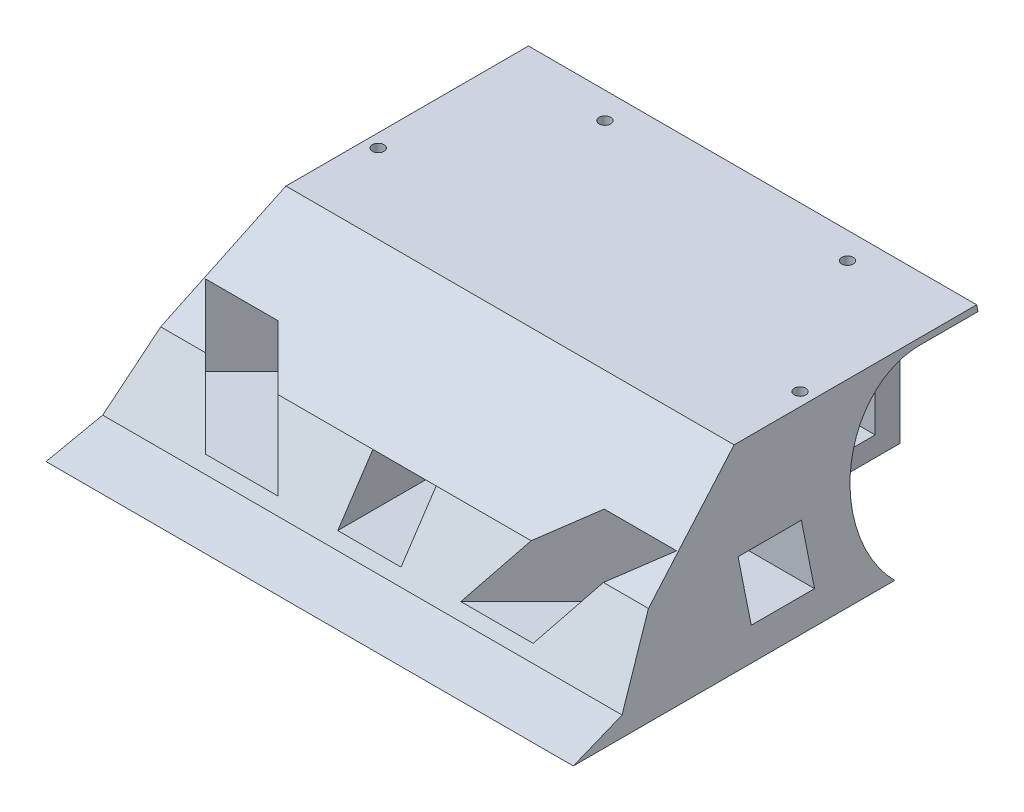
from build123d import *

# Parameters (mm, degrees)
IZIM2_W                       = 100
IZIM2_H                       = 90
Y_KSEKLIK_EKSTR_ZYON1_DEPTH   = 30
KES_EKSTR_ZYON11_DEPTH        = 22
KES_EKSTR_ZYON12_DEPTH        = 22
IZIM7_W                       = 12.5
IZIM7_H                       = 16.5
KES_EKSTR_ZYON13_DEPTH        = 70
IZIM8_W                       = 6
IZIM8_H                       = 30
KES_EKSTR_ZYON14_DEPTH        = 100
IZIM9_W                       = 22
IZIM9_H                       = 6
KES_EKSTR_ZYON15_DEPTH        = 100
IZIM10_W                      = 12
IZIM10_H                      = 10
KES_EKSTR_ZYON16_DEPTH        = 100
IZIM11_W                      = 12
IZIM11_H                      = 10
KES_EKSTR_ZYON17_DEPTH        = 45
Y_KSEKLIK_EKSTR_ZYON2_DEPTH   = 45
Y_KSEKLIK_EKSTR_ZYON2_2_DEPTH = 45
IZIM13_W                      = 9.7
IZIM13_H                      = 15.2
KES_EKSTR_ZYON18_DEPTH        = 45
IZIM14_W                      = 9.7
IZIM14_H                      = 15.2
KES_EKSTR_ZYON19_DEPTH        = 45
IZIM15_W                      = 64.648209686
IZIM15_H                      = 50.718484946
KES_EKSTR_ZYON20_DEPTH        = 45
KES_EKSTR_ZYON21_DEPTH        = 100
IZIM17_R                      = 1.1
KES_EKSTR_ZYON24_DEPTH        = 100
KES_EKSTR_ZYON25_DEPTH        = 100


with BuildPart() as part:
    # Çizim2 → Yükseklik-Ekstrüzyon1 (new body)
    with BuildSketch(Plane(origin=(0, 0, 0), x_dir=(1, 0, 0), z_dir=(0, 1, 0))):
        with Locations((-5.3298184, 8.1959709)):
            Rectangle(IZIM2_W, IZIM2_H)
    extrude(amount=Y_KSEKLIK_EKSTR_ZYON1_DEPTH)

    # Çizim5 → Kes-Ekstrüzyon11 (cut)
    with BuildSketch(Plane(origin=(44.6701816, 0, 0), x_dir=(0, 0, -1), z_dir=(1, 0, 0))):
        with BuildLine():
            Line((36.1959709, 29), (53.1959709, 29))
            Line((53.1959709, 29), (53.1959709, 0))
            Line((53.1959709, 0), (24.154376321, 0))
            ThreePointArc((24.154376321, 0), (20.495652432, 18.519202405), (36.1959709, 29))
        make_face()
    extrude(amount=-KES_EKSTR_ZYON11_DEPTH, mode=Mode.SUBTRACT)

    # Çizim6 → Kes-Ekstrüzyon12 (cut)
    with BuildSketch(Plane.ZY.offset(55.3298184)):
        with BuildLine():
            Line((-36.1959709, 29), (-53.1959709, 29))
            Line((-53.1959709, 29), (-53.1959709, 0))
            Line((-53.1959709, 0), (-24.154376321, 0))
            ThreePointArc((-24.154376321, 0), (-20.495652432, 18.519202405), (-36.1959709, 29))
        make_face()
    extrude(amount=-KES_EKSTR_ZYON12_DEPTH, mode=Mode.SUBTRACT)

    # Çizim7 → Kes-Ekstrüzyon13 (cut)
    with BuildSketch(Plane(origin=(22.6701816, 0, 0), x_dir=(0, 0, -1), z_dir=(1, 0, 0))):
        with Locations((36.1959709, 12)):
            Rectangle(IZIM7_W, IZIM7_H)
    extrude(amount=-KES_EKSTR_ZYON13_DEPTH, mode=Mode.SUBTRACT)

    # Çizim8 → Kes-Ekstrüzyon14 (cut)
    with BuildSketch(Plane(origin=(22.6701816, 0, 0), x_dir=(0, 0, -1), z_dir=(1, 0, 0))):
        with Locations((50.1959709, 15)):
            Rectangle(IZIM8_W, IZIM8_H)
    extrude(amount=-KES_EKSTR_ZYON14_DEPTH, mode=Mode.SUBTRACT)

    # Çizim9 → Kes-Ekstrüzyon15 (cut)
    with BuildSketch(Plane(origin=(0, 30, 0), x_dir=(1, 0, 0), z_dir=(0, 1, 0))):
        with Locations((33.6701816, 50.1959709)):
            Rectangle(IZIM9_W, IZIM9_H)
    extrude(amount=-KES_EKSTR_ZYON15_DEPTH, mode=Mode.SUBTRACT)

    # Çizim10 → Kes-Ekstrüzyon16 (cut)
    with BuildSketch(Plane(origin=(44.6701816, 0, 0), x_dir=(0, 0, -1), z_dir=(1, 0, 0))):
        with Locations((4.1959709, 10)):
            Rectangle(IZIM10_W, IZIM10_H)
    extrude(amount=-KES_EKSTR_ZYON16_DEPTH, mode=Mode.SUBTRACT)

    # Çizim11 → Kes-Ekstrüzyon17 (cut)
    with BuildSketch(Plane.XY.offset(36.8040291)):
        with Locations((-5.3298184, 10)):
            Rectangle(IZIM11_W, IZIM11_H)
    extrude(amount=-KES_EKSTR_ZYON17_DEPTH, mode=Mode.SUBTRACT)

    # Çizim13 → Kes-Ekstrüzyon18 (cut)
    with BuildSketch(Plane(origin=(12.73710535, 0, 12.73710535), x_dir=(0.707106781, 0, -0.707106781), z_dir=(0.707106781, 0, 0.707106781))):
        with Locations((-38.885769972, 12.6)):
            Rectangle(IZIM13_W, IZIM13_H)
    extrude(amount=-KES_EKSTR_ZYON18_DEPTH, mode=Mode.SUBTRACT)

    # Çizim14 → Kes-Ekstrüzyon19 (cut)
    with BuildSketch(Plane(origin=(-18.06692375, 0, 18.06692375), x_dir=(0.707106781, 0, 0.707106781), z_dir=(-0.707106781, 0, 0.707106781))):
        with Locations((31.348268505, 12.6)):
            Rectangle(IZIM14_W, IZIM14_H)
    extrude(amount=-KES_EKSTR_ZYON19_DEPTH, mode=Mode.SUBTRACT)

    # Çizim16 → Kes-Ekstrüzyon21 (cut)
    with BuildSketch(Plane(origin=(44.6701816, 0, 0), x_dir=(0, 0, -1), z_dir=(1, 0, 0))):
        Polygon((-36.8040291, 0), (-26.8040291, 3), (-18.8040291, 15), (1.1959709, 30), (-36.8040291, 30), align=None)
    extrude(amount=-KES_EKSTR_ZYON21_DEPTH, mode=Mode.SUBTRACT)

    # Çizim17 → Kes-Ekstrüzyon24 (cut)
    with BuildSketch(Plane(origin=(0, 30, 0), x_dir=(1, 0, 0), z_dir=(0, 1, 0))):
        with Locations((-28.3298184, 42.1959709)):
            Circle(IZIM17_R)
        with Locations((-45.3298184, 16.1959709)):
            Circle(IZIM17_R)
        with Locations((34.6701816, 16.1959709)):
            Circle(IZIM17_R)
        with Locations((17.6701816, 42.1959709)):
            Circle(IZIM17_R)
    extrude(amount=-KES_EKSTR_ZYON24_DEPTH, mode=Mode.SUBTRACT)

    # Çizim19 → Kes-Ekstrüzyon25 (cut)
    with BuildSketch(Plane(origin=(0, 0, -47.1959709), x_dir=(-1, 0, 0), z_dir=(0, 0, -1))):
        Polygon((-44.6701816, 0), (-37.1701816, 30), (-44.6701816, 30), align=None)
        Polygon((55.3298184, 0), (55.3298184, 30), (47.8298184, 30), align=None)
    extrude(amount=-KES_EKSTR_ZYON25_DEPTH, mode=Mode.SUBTRACT)


with BuildPart() as body_2:
    # Çizim12 → Yükseklik-Ekstrüzyon2 (new body)
    with BuildSketch(Plane(origin=(0, 30, 0), x_dir=(1, 0, 0), z_dir=(0, 1, 0))):
        Polygon((-11.3298184, -36.8040291), (-17.233785956, -42.707996656), (-17.233785956, -36.8040291), align=None)
    extrude(amount=Y_KSEKLIK_EKSTR_ZYON2_DEPTH)


with BuildPart() as body_3:
    # Çizim12 → Y_kseklik-Ekstr_zyon2 2 (new body)
    with BuildSketch(Plane(origin=(0, 30, 0), x_dir=(1, 0, 0), z_dir=(0, 1, 0))):
        Polygon((0.6701816, -36.8040291), (4.718486826, -40.852334326), (4.718486826, -36.8040291), align=None)
    extrude(amount=Y_KSEKLIK_EKSTR_ZYON2_2_DEPTH)


with BuildPart() as kes_ekstr_zyon20_tool:
    # Çizim15 → Kes-Ekstrüzyon20 (new body)
    with BuildSketch(Plane(origin=(0, 30, 0), x_dir=(1, 0, 0), z_dir=(0, 1, 0))):
        with Locations((5.316439318, -44.683310577)):
            Rectangle(IZIM15_W, IZIM15_H)
    extrude(amount=KES_EKSTR_ZYON20_DEPTH)


with BuildPart() as body_2_1:
    add(body_2.part)

    # Kes-Ekstrüzyon20: cut by kes_ekstr_zyon20_tool
    add(kes_ekstr_zyon20_tool.part, mode=Mode.SUBTRACT)


with BuildPart() as body_3_1:
    add(body_3.part)

    # Kes-Ekstrüzyon20: cut by kes_ekstr_zyon20_tool
    add(kes_ekstr_zyon20_tool.part, mode=Mode.SUBTRACT)


solid = part.part
